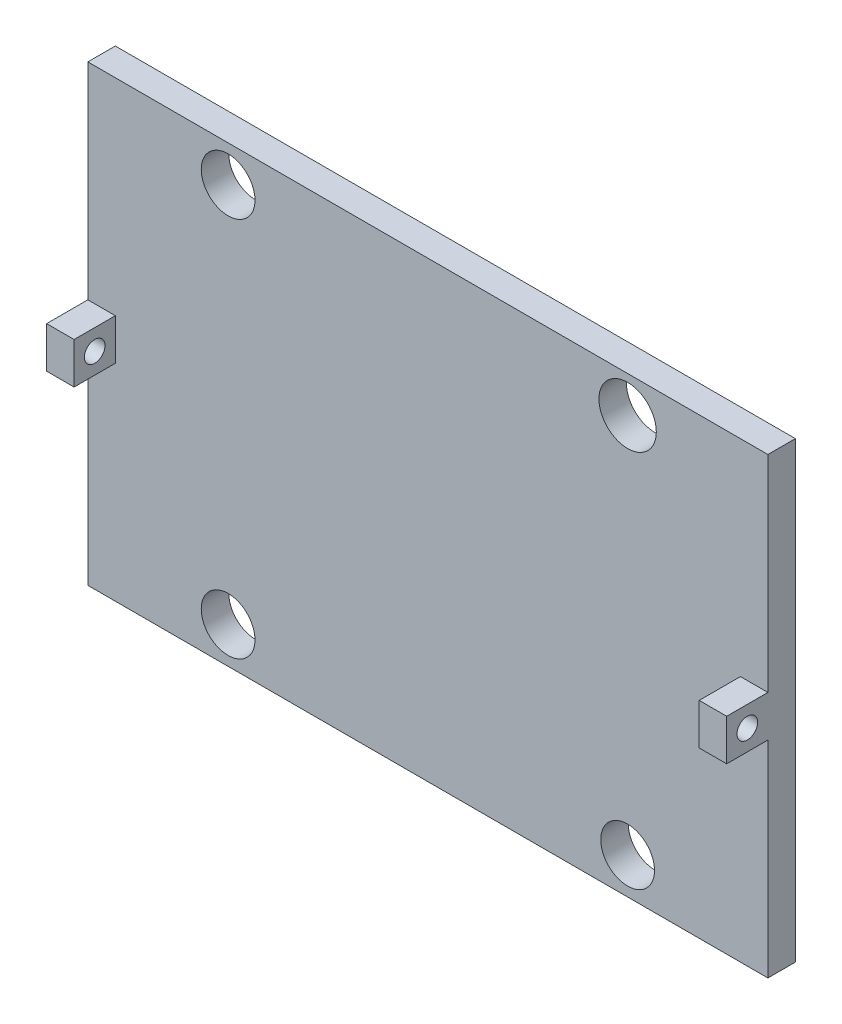
from build123d import *

# Parameters (mm, degrees)
SKETCH1_W           = 49.5
SKETCH1_H           = 33
BOSS_EXTRUDE1_DEPTH = 2
BOSS_EXTRUDE4_DEPTH = 3
SKETCH9_R           = 0.75
CUT_EXTRUDE3_DEPTH  = 70
SKETCH10_R          = 2.087011894
SKETCH10_R_2        = 1.9558
CUT_EXTRUDE4_DEPTH  = 70


with BuildPart() as part:
    # Sketch1 → Boss-Extrude1 (new body)
    with BuildSketch(Plane.XY):
        with Locations((-6.974438903, -6.316084788)):
            Rectangle(SKETCH1_W, SKETCH1_H)
    extrude(amount=BOSS_EXTRUDE1_DEPTH)

    # Sketch8 → Boss-Extrude4 (add)
    with BuildSketch(Plane.XY.offset(2)):
        Polygon((-31.724438903, -6.316084788), (-31.724438903, -4.816084788), (-29.724438903, -4.816084788), (-29.724438903, -7.816084788), (-31.724438903, -7.816084788), align=None)
        Polygon((17.775561097, -4.816084788), (17.775561097, -7.816084788), (15.775561097, -7.816084788), (15.775561097, -6.316084788), (15.775561097, -4.816084788), align=None)
    extrude(amount=BOSS_EXTRUDE4_DEPTH)

    # Sketch9 → Cut-Extrude3 (cut)
    with BuildSketch(Plane.ZY.offset(31.724438903)):
        with Locations((3.5, -6.316084788)):
            Circle(SKETCH9_R)
    extrude(amount=-CUT_EXTRUDE3_DEPTH, mode=Mode.SUBTRACT)

    # Sketch10 → Cut-Extrude4 (cut)
    with BuildSketch(Plane(origin=(0, 0, 0), x_dir=(-1, 0, 0), z_dir=(0, 0, -1))):
        with Locations((-7.565561097, 7.539615212)):
            Circle(SKETCH10_R)
        with Locations((21.514438903, 7.539615212)):
            Circle(SKETCH10_R_2)
        with Locations((-7.565561097, -20.171784788)):
            Circle(SKETCH10_R_2)
        with Locations((21.514438903, -20.171784788)):
            Circle(SKETCH10_R_2)
    extrude(amount=-CUT_EXTRUDE4_DEPTH, mode=Mode.SUBTRACT)


solid = part.part
